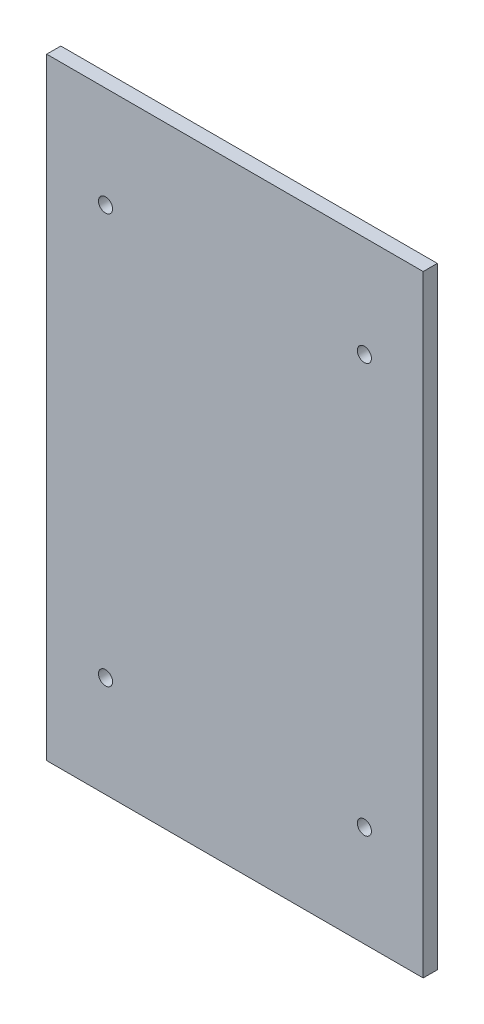
from build123d import *

# Parameters (mm, degrees)
ESBO_O1_W                = 80
ESBO_O1_H                = 130
RESSALTO_EXTRUS_O1_DEPTH = 3
ESBO_O2_R                = 1.5
CORTE_EXTRUS_O1_DEPTH    = 3
ESBO_O2_3_R              = 1.5
CORTE_EXTRUS_O2_DEPTH    = 3
ESBO_O2_4_R              = 1.5
CORTE_EXTRUS_O3_DEPTH    = 3


with BuildPart() as part:
    # Esboço1 → Ressalto-extrusão1 (new body)
    with BuildSketch(Plane.XY):
        with Locations((-27.5, -29.311993606)):
            Rectangle(ESBO_O1_W, ESBO_O1_H)
    extrude(amount=RESSALTO_EXTRUS_O1_DEPTH)

    # Esboço2 → Corte-extrusão1 (cut)
    with BuildSketch(Plane.XY.offset(3)):
        with Locations((-55, 14.188006394)):
            Circle(ESBO_O2_R)
    extrude(amount=-CORTE_EXTRUS_O1_DEPTH, mode=Mode.SUBTRACT)

    # Esboço2<3> → Corte-extrusão2 (cut)
    with BuildSketch(Plane.XY.offset(3)):
        with Locations((0, 14.188006394)):
            Circle(ESBO_O2_3_R)
    extrude(amount=-CORTE_EXTRUS_O2_DEPTH, mode=Mode.SUBTRACT)

    # Esboço2<4> → Corte-extrusão3 (cut)
    with BuildSketch(Plane.XY.offset(3)):
        with Locations((0, -72.811993606)):
            Circle(ESBO_O2_4_R)
        with Locations((-55, -72.811993606)):
            Circle(ESBO_O2_4_R)
    extrude(amount=-CORTE_EXTRUS_O3_DEPTH, mode=Mode.SUBTRACT)


solid = part.part
